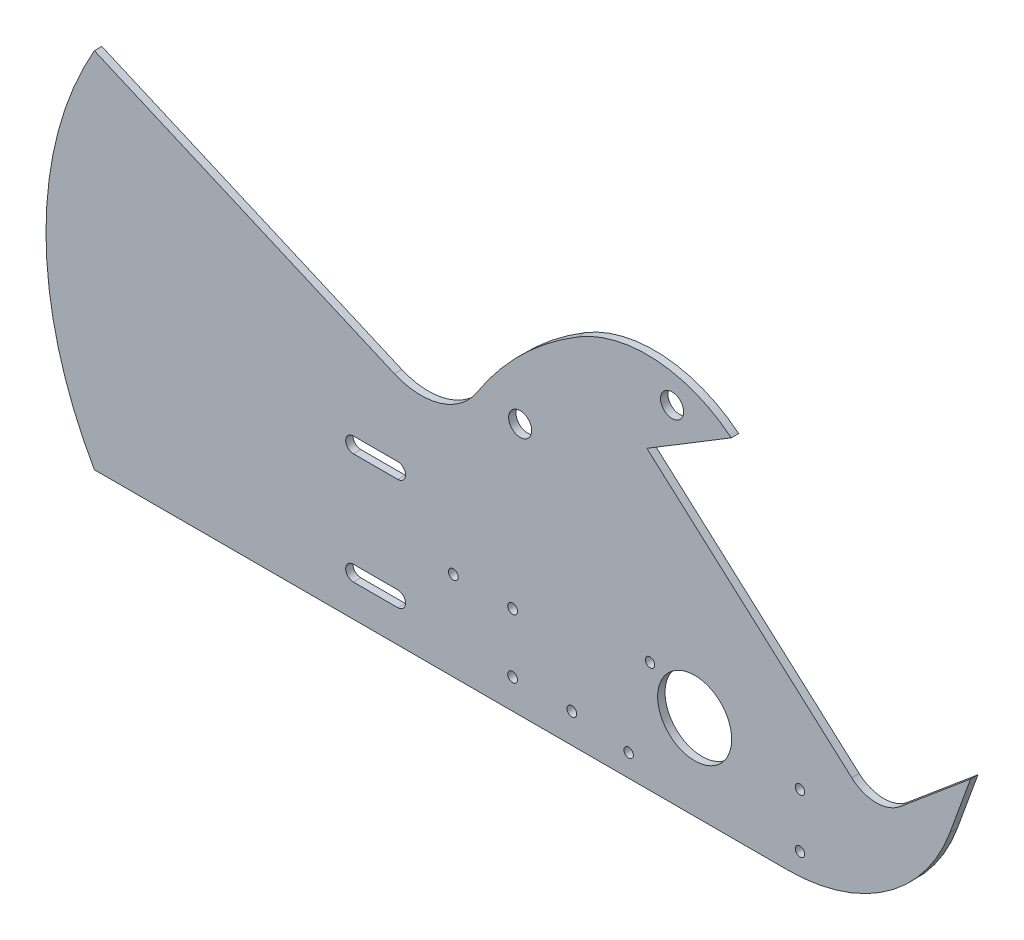
from build123d import *

# Parameters (mm, degrees)
BOSS_EXTRUDE1_DEPTH              = 3.175
SKETCH4_R                        = 15.875
CUT_EXTRUDE1_DEPTH               = 4.175
SKETCH10_R                       = 2.0955
CUT_EXTRUDE5_DEPTH               = 4.175
CUT_EXTRUDE6_DEPTH               = 3.175
SKETCH12_R                       = 2.0193
CUT_EXTRUDE7_DEPTH               = 3.175
F_25_64_0_39063_DIAMETER_HOLE1_D = 9.922002


with BuildPart() as part:
    # Sketch1 → Boss-Extrude1 (new body)
    with BuildSketch(Plane.XY):
        with BuildLine():
            Line((-127.585439757, -38.931312956), (20.895912371, -38.931312956))
            ThreePointArc((20.895912371, -38.931312956), (63.319116371, -25.555328115), (90.398020935, 9.734587382))
            Line((90.398020935, 9.734587382), (99.264008145, 34.093687044))
            Line((99.264008145, 34.093687044), (69.069421488, 8.757420515))
            ThreePointArc((69.069421488, 8.757420515), (58.622007829, 5.045238426), (48.293203475, 9.075691085))
            Line((48.293203475, 9.075691085), (-39.53568268, 87.480536572))
            Line((-39.53568268, 87.480536572), (-3.340712695, 109.466412576))
            ThreePointArc((-3.340712695, 109.466412576), (-35.575547408, 122.196999074), (-69.251886775, 114.008191568))
            ThreePointArc((-69.251886775, 114.008191568), (-93.222829654, 95.410668155), (-112.371322471, 71.877517018))
            ThreePointArc((-112.371322471, 71.877517018), (-128.087342247, 59.948856215), (-147.787037557, 61.048051754))
            Line((-147.787037557, 61.048051754), (-177.372260989, 73.844569494))
            Line((-177.372260989, 73.844569494), (-276.451380272, 116.699331448))
            ThreePointArc((-276.451380272, 116.699331448), (-297.183919754, 38.884009246), (-276.451380272, -38.931312956))
            Line((-276.451380272, -38.931312956), (-127.585439757, -38.931312956))
        make_face()
    extrude(amount=BOSS_EXTRUDE1_DEPTH)

    # Sketch4 → Cut-Extrude1 (cut, through all)
    with BuildSketch(Plane.XY):
        with Locations((-19.051033526, -2.418812956)):
            Circle(SKETCH4_R)
    extrude(amount=CUT_EXTRUDE1_DEPTH, mode=Mode.SUBTRACT)

    # Sketch10 → Cut-Extrude5 (cut, through all)
    with BuildSketch(Plane.XY.offset(3.175)):
        with Locations((-97.11436, -26.231312956)):
            Circle(SKETCH10_R)
        with Locations((-71.71436, -26.231312956)):
            Circle(SKETCH10_R)
        with Locations((-122.51436, -0.831312956)):
            Circle(SKETCH10_R)
        with Locations((-97.11436, -0.831312956)):
            Circle(SKETCH10_R)
    extrude(amount=-CUT_EXTRUDE5_DEPTH, mode=Mode.SUBTRACT)

    # Sketch11 → Cut-Extrude6 (cut)
    with BuildSketch(Plane.XY.offset(3.175)):
        with BuildLine():
            Line((-165.387218926, -25.088312956), (-146.337218926, -25.088312956))
            ThreePointArc((-146.337218926, -25.088312956), (-143.035218926, -21.786312956), (-146.337218926, -18.484312956))
            Line((-146.337218926, -18.484312956), (-165.387218926, -18.484312956))
            ThreePointArc((-165.387218926, -18.484312956), (-168.689218926, -21.786312956), (-165.387218926, -25.088312956))
        make_face()
        with BuildLine():
            Line((-165.387218926, 29.140687044), (-146.337218926, 29.140687044))
            ThreePointArc((-146.337218926, 29.140687044), (-143.035218926, 25.838687044), (-146.337218926, 22.536687044))
            Line((-146.337218926, 22.536687044), (-165.387218926, 22.536687044))
            ThreePointArc((-165.387218926, 22.536687044), (-168.689218926, 25.838687044), (-165.387218926, 29.140687044))
        make_face()
    extrude(amount=-CUT_EXTRUDE6_DEPTH, mode=Mode.SUBTRACT)

    # Sketch12 → Cut-Extrude7 (cut)
    with BuildSketch(Plane.XY.offset(3.175)):
        with Locations((26.111583591, -6.330574271)):
            Circle(SKETCH12_R)
        with Locations((-38.190866701, 8.693687044)):
            Circle(SKETCH12_R)
        with Locations((-47.354412394, -29.406312956)):
            Circle(SKETCH12_R)
        with Locations((26.111583591, -29.406312956)):
            Circle(SKETCH12_R)
    extrude(amount=-CUT_EXTRUDE7_DEPTH, mode=Mode.SUBTRACT)

    # 25/64 (0.39063) Diameter Hole1 (through all)
    with Locations(Plane.XY.offset(3.175)):
        with Locations((-28.740712695, 108.89709501), (-93.867251666, 69.337343725)):
            Hole(F_25_64_0_39063_DIAMETER_HOLE1_D / 2)


solid = part.part
